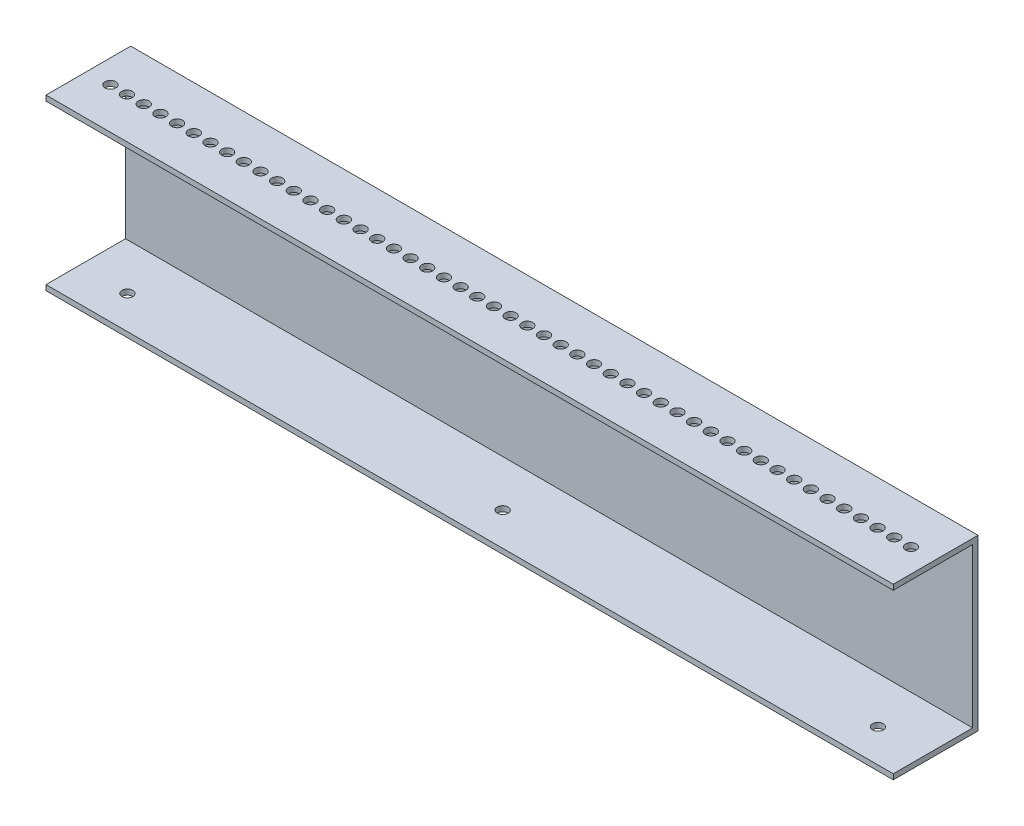
from build123d import *

# Parameters (mm, degrees)
ALUM_C_CHNL_SHORT_BOSS_EXTRUDE3_DEPTH      = 254
ALUM_C_CHNL_SHORT_BOSS_EXTRUDE3_DEPTH_BACK = 254
SKETCH12_R                                 = 3.25
CUT_EXTRUDE9_DEPTH                         = 3.175
SKETCH8_R                                  = 3.25
CUT_EXTRUDE5_DEPTH                         = 20
LPATTERN4_COUNT                            = 25
LPATTERN4_PITCH                            = 10
LPATTERN3_COUNT                            = 25
LPATTERN3_PITCH                            = 10


with BuildPart() as part:
    # Sketch3 → Alum C chnl SHORT Boss-Extrude3 (new body, two sides)
    with BuildSketch(Plane(origin=(0, 0, 0), x_dir=(0, 0, -1), z_dir=(1, 0, 0))) as alum_c_chnl_short_boss_extrude3_sk:
        Polygon((-304.8, 12.7), (-254, 12.7), (-254, 114.3), (-304.8, 114.3), (-304.8, 111.125), (-257.175, 111.125), (-257.175, 15.875), (-304.8, 15.875), align=None)
    extrude(amount=ALUM_C_CHNL_SHORT_BOSS_EXTRUDE3_DEPTH)
    extrude(alum_c_chnl_short_boss_extrude3_sk.sketch, amount=-ALUM_C_CHNL_SHORT_BOSS_EXTRUDE3_DEPTH_BACK)

    # Sketch12 → Cut-Extrude9 (cut)
    with BuildSketch(Plane(origin=(0, 15.875, 0), x_dir=(1, 0, 0), z_dir=(0, 1, 0))):
        with Locations((-225, -285)):
            Circle(SKETCH12_R)
        with Locations((0, -285)):
            Circle(SKETCH12_R)
        with Locations((225, -285)):
            Circle(SKETCH12_R)
    extrude(amount=-CUT_EXTRUDE9_DEPTH, mode=Mode.SUBTRACT)

    # Sketch8 → Cut-Extrude5 (cut)
    with BuildSketch(Plane(origin=(0, 114.3, 0), x_dir=(1, 0, 0), z_dir=(0, 1, 0))):
        with Locations((0, -280.2)):
            Circle(SKETCH8_R)
    cut_extrude5 = extrude(amount=-CUT_EXTRUDE5_DEPTH, mode=Mode.SUBTRACT)

    # LPattern4: Cut-Extrude5 ×25
    with Locations(*[(-i * LPATTERN4_PITCH, 0, 0) for i in range(1, LPATTERN4_COUNT)]):
        add(cut_extrude5, mode=Mode.SUBTRACT)

    # LPattern3: Cut-Extrude5 ×25
    with Locations(*[(i * LPATTERN3_PITCH, 0, 0) for i in range(1, LPATTERN3_COUNT)]):
        add(cut_extrude5, mode=Mode.SUBTRACT)


solid = part.part
